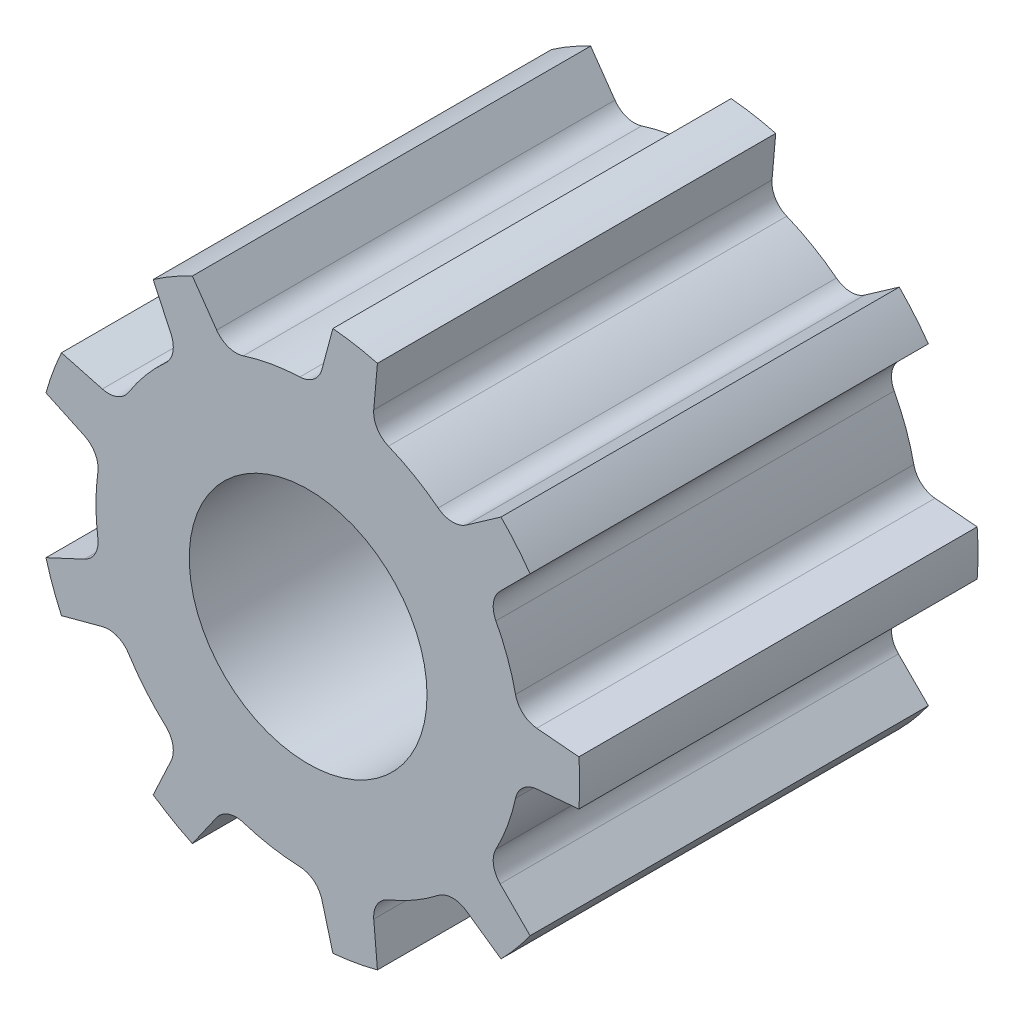
from build123d import *

# Parameters (mm, degrees)
SKETCH2_R           = 2
BOSS_EXTRUDE1_DEPTH = 6.7


with BuildPart() as part:
    # Sketch2 → Boss-Extrude1 (new body)
    with BuildSketch(Plane.XY):
        with BuildLine():
            Line((-4.409637173, -1.2), (-3.764514138, -0.899174188))
            ThreePointArc((-3.764514138, -0.899174188), (-3.582420347, -0.728223333), (-3.537232834, -0.482580436))
            ThreePointArc((-3.537232834, -0.482580436), (-3.57, 0), (-3.537232834, 0.482580436))
            ThreePointArc((-3.537232834, 0.482580436), (-3.582420347, 0.728223333), (-3.764514138, 0.899174188))
            Line((-3.764514138, 0.899174188), (-4.409637173, 1.2))
            ThreePointArc((-4.409637173, 1.2), (-4.294395277, 1.563032055), (-4.149323184, 1.915206806))
            Line((-4.149323184, 1.915206806), (-3.461763164, 1.730975654))
            ThreePointArc((-3.461763164, 1.730975654), (-3.212386135, 1.744883974), (-3.019874282, 1.904011377))
            ThreePointArc((-3.019874282, 1.904011377), (-2.734778662, 2.294751767), (-2.399480831, 2.6433675))
            ThreePointArc((-2.399480831, 2.6433675), (-2.276200264, 2.860586849), (-2.305807109, 3.108590435))
            Line((-2.305807109, 3.108590435), (-2.606632921, 3.75371347))
            ThreePointArc((-2.606632921, 3.75371347), (-2.285, 3.957736095), (-1.947494763, 4.134267063))
            Line((-1.947494763, 4.134267063), (-1.539214732, 3.55118275))
            ThreePointArc((-1.539214732, 3.55118275), (-1.339240749, 3.401540677), (-1.089482991, 3.399695106))
            ThreePointArc((-1.089482991, 3.399695106), (-0.619923994, 3.515763678), (-0.13898508, 3.567293533))
            ThreePointArc((-0.13898508, 3.567293533), (0.095079219, 3.654449987), (0.231812692, 3.863462669))
            Line((0.231812692, 3.863462669), (0.416043844, 4.551022689))
            ThreePointArc((0.416043844, 4.551022689), (0.793572172, 4.500571431), (1.165588102, 4.418857814))
            Line((1.165588102, 4.418857814), (1.10354938, 3.709751971))
            ThreePointArc((1.10354938, 3.709751971), (1.160550267, 3.466578694), (1.3506895, 3.304623712))
            ThreePointArc((1.3506895, 3.304623712), (1.785, 3.091710692), (2.186543334, 2.822043275))
            ThreePointArc((2.186543334, 2.822043275), (2.421870079, 2.738355361), (2.660964759, 2.810577782))
            Line((2.660964759, 2.810577782), (3.244049071, 3.218857814))
            ThreePointArc((3.244049071, 3.218857814), (3.500823105, 2.937539376), (3.73327934, 2.635815883))
            Line((3.73327934, 2.635815883), (3.229950472, 2.132487015))
            ThreePointArc((3.229950472, 2.132487015), (3.117306916, 1.909566013), (3.158859362, 1.663282156))
            ThreePointArc((3.158859362, 1.663282156), (3.354702656, 1.221011912), (3.488963822, 0.756327606))
            ThreePointArc((3.488963822, 0.756327606), (3.615441013, 0.540953828), (3.845021841, 0.442592316))
            Line((3.845021841, 0.442592316), (4.554127684, 0.380553593))
            ThreePointArc((4.554127684, 0.380553593), (4.57, 0), (4.554127684, -0.380553593))
            Line((4.554127684, -0.380553593), (3.845021841, -0.442592316))
            ThreePointArc((3.845021841, -0.442592316), (3.615441013, -0.540953828), (3.488963822, -0.756327606))
            ThreePointArc((3.488963822, -0.756327606), (3.354702656, -1.221011912), (3.158859362, -1.663282156))
            ThreePointArc((3.158859362, -1.663282156), (3.117306916, -1.909566013), (3.229950472, -2.132487015))
            Line((3.229950472, -2.132487015), (3.73327934, -2.635815883))
            ThreePointArc((3.73327934, -2.635815883), (3.500823105, -2.937539376), (3.244049071, -3.218857814))
            Line((3.244049071, -3.218857814), (2.660964759, -2.810577782))
            ThreePointArc((2.660964759, -2.810577782), (2.421870079, -2.738355361), (2.186543334, -2.822043275))
            ThreePointArc((2.186543334, -2.822043275), (1.785, -3.091710692), (1.3506895, -3.304623712))
            ThreePointArc((1.3506895, -3.304623712), (1.160550267, -3.466578694), (1.10354938, -3.709751971))
            Line((1.10354938, -3.709751971), (1.165588102, -4.418857814))
            ThreePointArc((1.165588102, -4.418857814), (0.793572172, -4.500571431), (0.416043844, -4.551022689))
            Line((0.416043844, -4.551022689), (0.231812692, -3.863462669))
            ThreePointArc((0.231812692, -3.863462669), (0.095079219, -3.654449987), (-0.13898508, -3.567293533))
            ThreePointArc((-0.13898508, -3.567293533), (-0.619923994, -3.515763678), (-1.089482991, -3.399695106))
            ThreePointArc((-1.089482991, -3.399695106), (-1.339240749, -3.401540677), (-1.539214732, -3.55118275))
            Line((-1.539214732, -3.55118275), (-1.947494763, -4.134267063))
            ThreePointArc((-1.947494763, -4.134267063), (-2.285, -3.957736095), (-2.606632921, -3.75371347))
            Line((-2.606632921, -3.75371347), (-2.305807109, -3.108590435))
            ThreePointArc((-2.305807109, -3.108590435), (-2.276200264, -2.860586849), (-2.399480831, -2.6433675))
            ThreePointArc((-2.399480831, -2.6433675), (-2.734778662, -2.294751767), (-3.019874282, -1.904011377))
            ThreePointArc((-3.019874282, -1.904011377), (-3.212386135, -1.744883974), (-3.461763164, -1.730975654))
            Line((-3.461763164, -1.730975654), (-4.149323184, -1.915206806))
            ThreePointArc((-4.149323184, -1.915206806), (-4.294395277, -1.563032055), (-4.409637173, -1.2))
        make_face()
        Circle(SKETCH2_R, mode=Mode.SUBTRACT)
    extrude(amount=BOSS_EXTRUDE1_DEPTH)


solid = part.part
